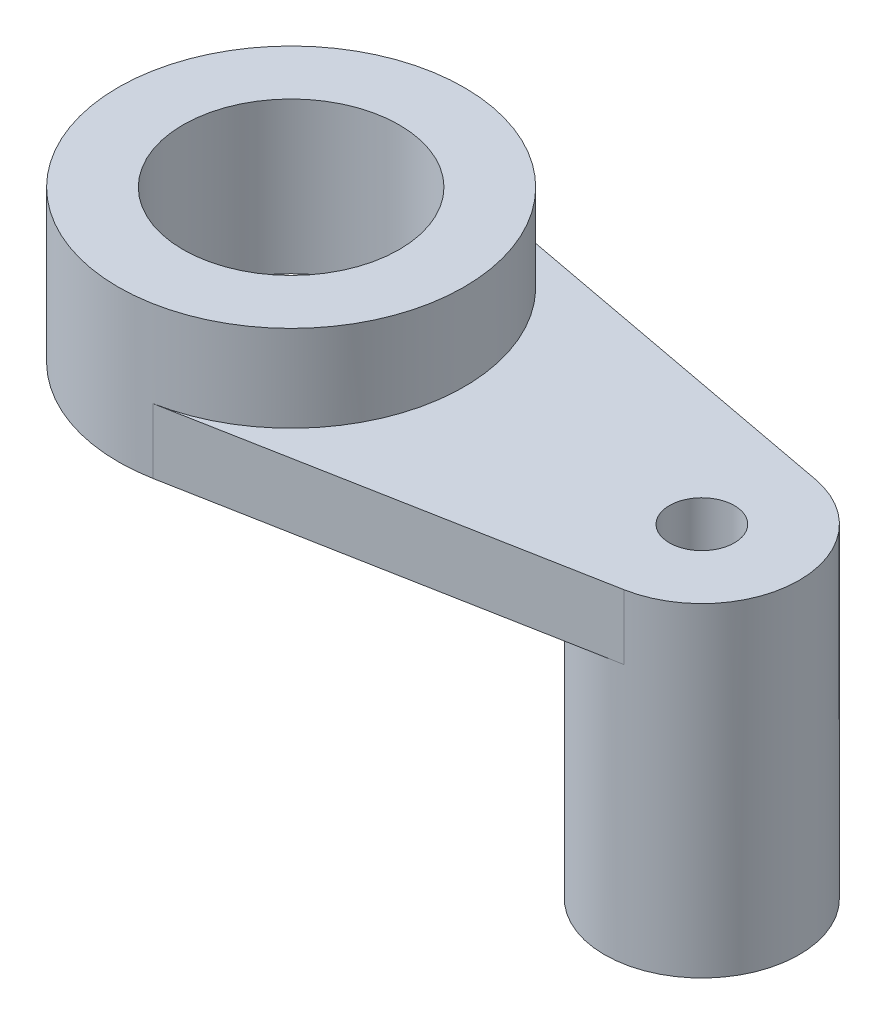
from build123d import *

# Parameters (mm, degrees)
BOSS_EXTRUDE1_DEPTH      = 6
SKETCH2_3_R              = 16
SKETCH2_3_R_2            = 10
BOSS_EXTRUDE2_DEPTH      = 14
SKETCH2_4_R              = 9
SKETCH2_4_R_2            = 3
BOSS_EXTRUDE3_DEPTH      = 6
BOSS_EXTRUDE3_DEPTH_BACK = 24


with BuildPart() as part:
    # Sketch2 → Boss-Extrude1 (new body)
    with BuildSketch(Plane(origin=(0, 0, 0), x_dir=(1, 0, 0), z_dir=(0, 1, 0))):
        with BuildLine():
            Line((39.657894737, 8.845981293), (2.947368421, 15.726188966))
            ThreePointArc((2.947368421, 15.726188966), (12.311740225, 10.218661979), (16, 0))
            ThreePointArc((16, 0), (12.311740225, -10.218661979), (2.947368421, -15.726188966))
            Line((2.947368421, -15.726188966), (39.657894737, -8.845981293))
            ThreePointArc((39.657894737, -8.845981293), (29, 0), (39.657894737, 8.845981293))
        make_face()
    extrude(amount=BOSS_EXTRUDE1_DEPTH)

    # Sketch2_3 → Boss-Extrude2 (add)
    with BuildSketch(Plane(origin=(0, 0, 0), x_dir=(1, 0, 0), z_dir=(0, 1, 0))):
        Circle(SKETCH2_3_R)
        Circle(SKETCH2_3_R_2, mode=Mode.SUBTRACT)
    extrude(amount=BOSS_EXTRUDE2_DEPTH)

    # Sketch2_4 → Boss-Extrude3 (add, two sides)
    with BuildSketch(Plane(origin=(0, 0, 0), x_dir=(1, 0, 0), z_dir=(0, 1, 0))) as boss_extrude3_sk:
        with Locations((38, 0)):
            Circle(SKETCH2_4_R)
        with Locations((38, 0)):
            Circle(SKETCH2_4_R_2, mode=Mode.SUBTRACT)
    extrude(amount=BOSS_EXTRUDE3_DEPTH)
    extrude(boss_extrude3_sk.sketch, amount=-BOSS_EXTRUDE3_DEPTH_BACK)


solid = part.part
